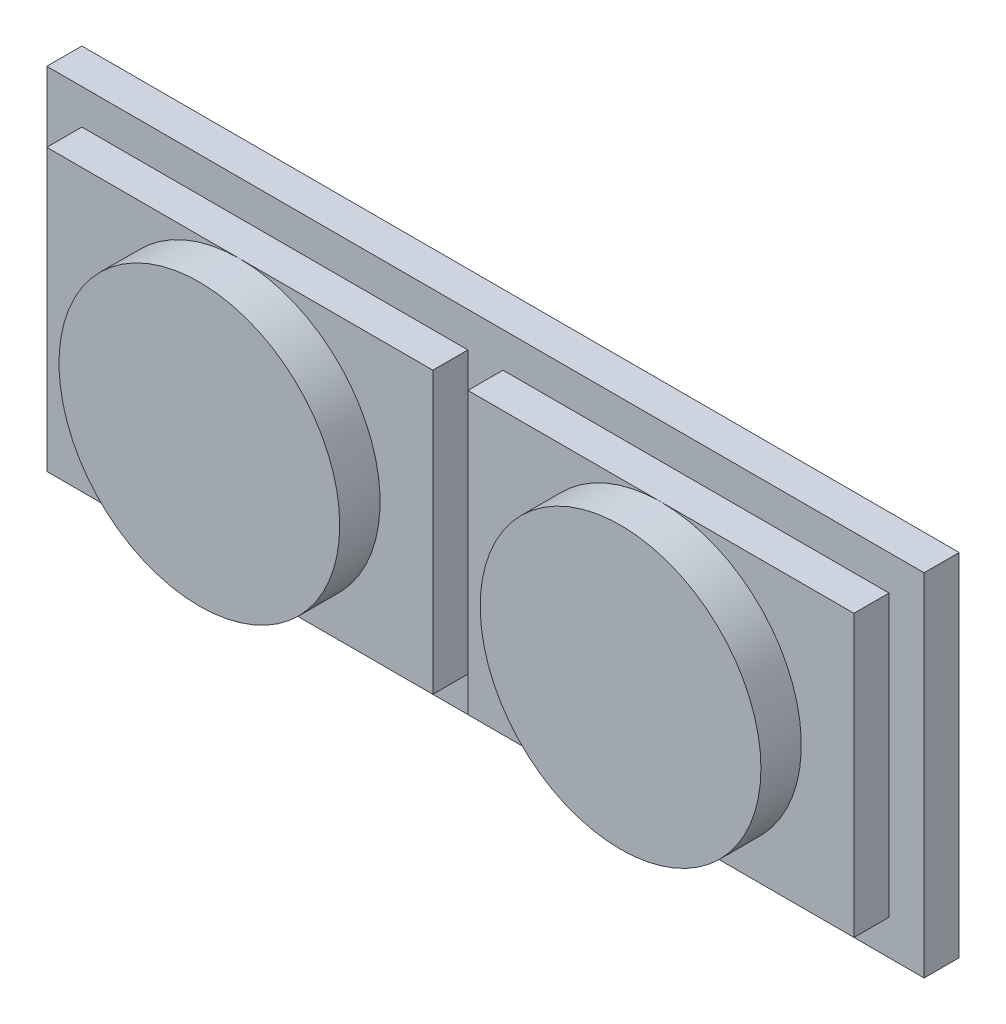
from build123d import *

# Parameters (mm, degrees)
SKETCH1_W             = 6.35
SKETCH1_H             = 2.54
BOSS_EXTRUDE1_DEPTH   = 0.254
SKETCH2_W             = 2.794
SKETCH2_H             = 2.032
BOSS_EXTRUDE3_DEPTH   = 0.254
BOSS_EXTRUDE3_2_DEPTH = 0.254
SKETCH4_R             = 1.016
BOSS_EXTRUDE4_DEPTH   = 0.2921
SKETCH5_R             = 1.016
BOSS_EXTRUDE5_DEPTH   = 0.2921


with BuildPart() as part:
    # Sketch1 → Boss-Extrude1 (new body)
    with BuildSketch(Plane.XY):
        with Locations((3.175, 1.27)):
            Rectangle(SKETCH1_W, SKETCH1_H)
    extrude(amount=BOSS_EXTRUDE1_DEPTH)


with BuildPart() as body_2:
    # Sketch2 → Boss-Extrude3 (new body)
    with BuildSketch(Plane.XY.offset(0.254)):
        with Locations((1.651, 1.27)):
            Rectangle(SKETCH2_W, SKETCH2_H)
    extrude(amount=BOSS_EXTRUDE3_DEPTH)

    # Sketch4 → Boss-Extrude4 (add)
    with BuildSketch(Plane.XY.offset(0.508)):
        with Locations((1.650390219, 1.27)):
            Circle(SKETCH4_R)
    extrude(amount=BOSS_EXTRUDE4_DEPTH)


with BuildPart() as body_3:
    # Sketch2 → Boss-Extrude3 2 (new body)
    with BuildSketch(Plane.XY.offset(0.254)):
        with Locations((4.699, 1.27)):
            Rectangle(SKETCH2_W, SKETCH2_H)
    extrude(amount=BOSS_EXTRUDE3_2_DEPTH)

    # Sketch5 → Boss-Extrude5 (add)
    with BuildSketch(Plane.XY.offset(0.508)):
        with Locations((4.699, 1.27)):
            Circle(SKETCH5_R)
    extrude(amount=BOSS_EXTRUDE5_DEPTH)


solid = Compound([part.part, body_2.part, body_3.part])
